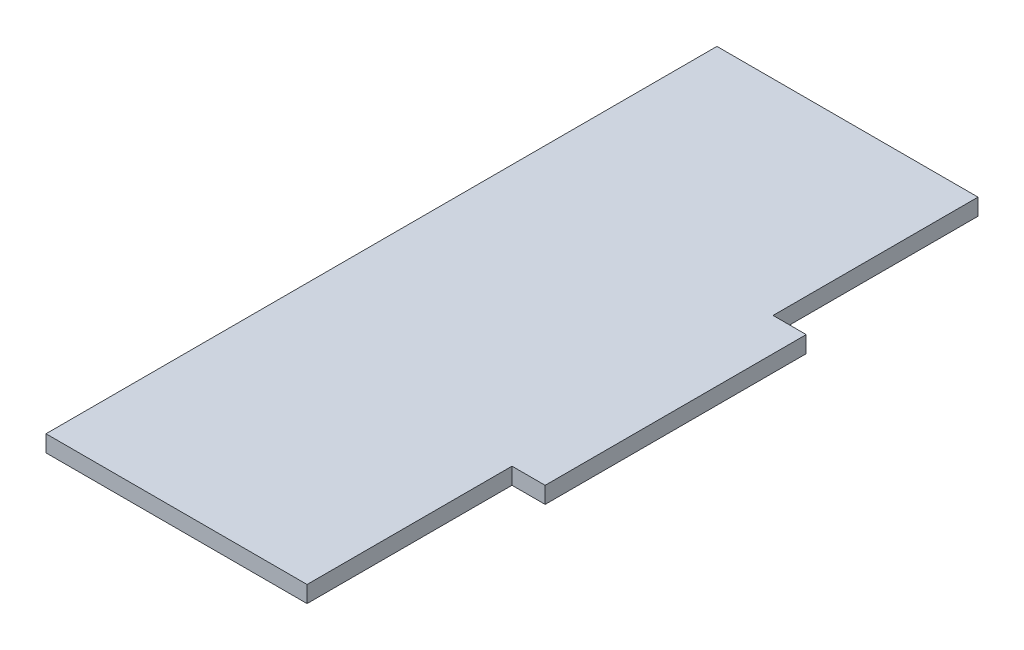
from build123d import *

# Parameters (mm, degrees)
BOSS_EXTRUDE1_DEPTH = 3.175


with BuildPart() as part:
    # Sketch1 → Boss-Extrude1 (new body)
    with BuildSketch(Plane(origin=(0, 0, 0), x_dir=(1, 0, 0), z_dir=(0, 1, 0))):
        Polygon((-25, 0), (-25, 39.25), (25, 39.25), (25, 0), (31.35, 0), (31.35, -50), (25, -50), (25, -89.25), (-25, -89.25), (-25, -50), align=None)
    extrude(amount=BOSS_EXTRUDE1_DEPTH)


solid = part.part
